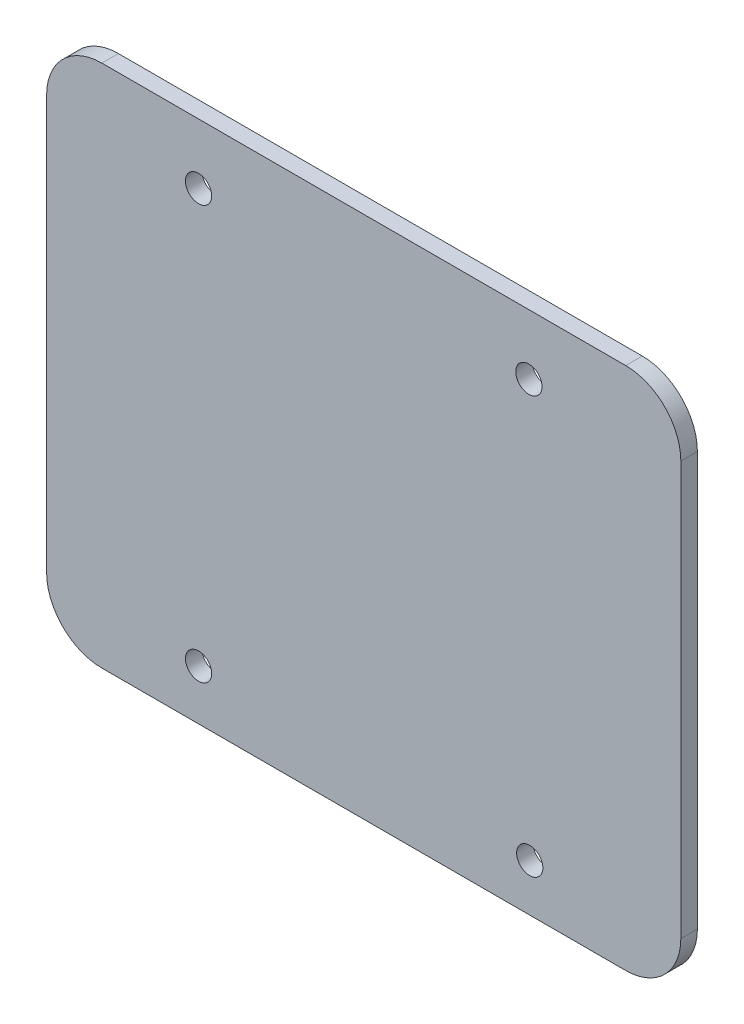
from build123d import *

# Parameters (mm, degrees)
CROQUIS1_R              = 2.38125
SALIENTE_EXTRUIR1_DEPTH = 3


with BuildPart() as part:
    # Croquis1 → Saliente-Extruir1 (new body)
    with BuildSketch(Plane.XY):
        with BuildLine():
            Line((10, 0), (105, 0))
            ThreePointArc((105, 0), (112.071067812, 2.928932188), (115, 10))
            Line((115, 10), (115, 85))
            ThreePointArc((115, 85), (112.071067812, 92.071067812), (105, 95))
            Line((105, 95), (10, 95))
            ThreePointArc((10, 95), (2.928932188, 92.071067812), (0, 85))
            Line((0, 85), (0, 10))
            ThreePointArc((0, 10), (2.928932188, 2.928932188), (10, 0))
        make_face()
        with Locations((27.55, 84.08)):
            Circle(CROQUIS1_R, mode=Mode.SUBTRACT)
        with Locations((87.45, 84.08)):
            Circle(CROQUIS1_R, mode=Mode.SUBTRACT)
        with Locations((27.55, 9.08)):
            Circle(CROQUIS1_R, mode=Mode.SUBTRACT)
        with Locations((87.6, 8.580149007)):
            Circle(CROQUIS1_R, mode=Mode.SUBTRACT)
    extrude(amount=SALIENTE_EXTRUIR1_DEPTH)


solid = part.part
